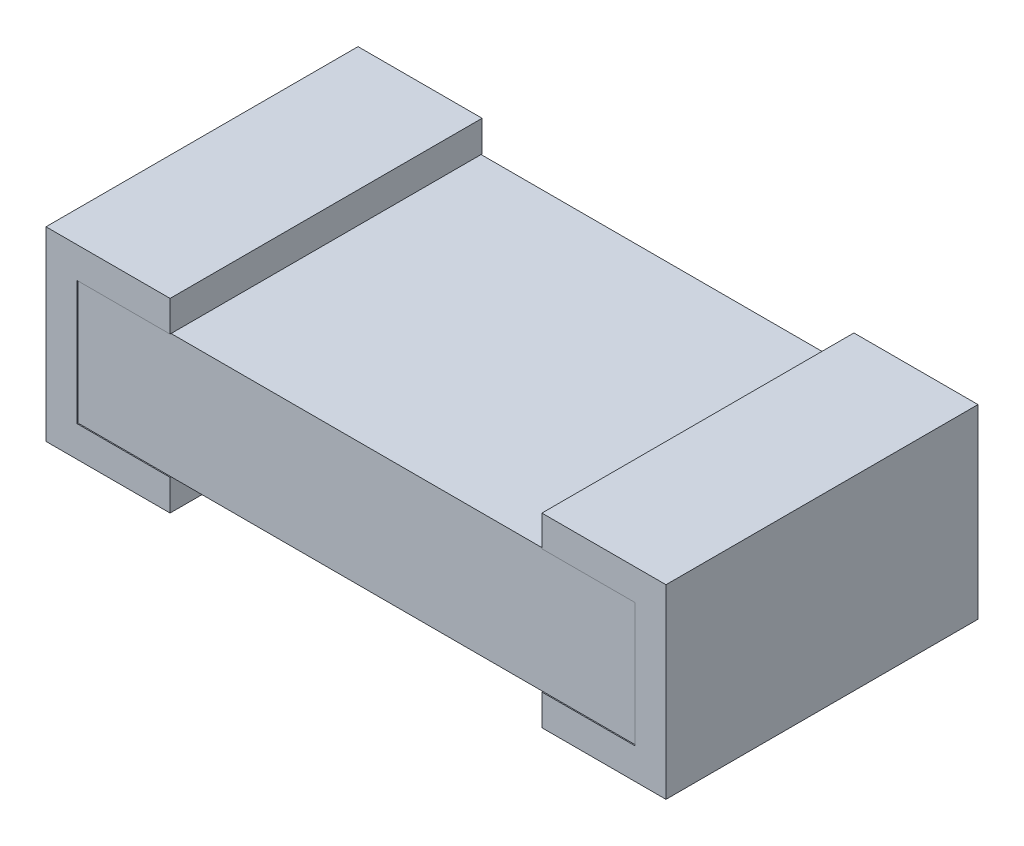
from build123d import *

# Parameters (mm, degrees)
ESBO_O1_W                = 1.372
ESBO_O1_H                = 0.305
RESSALTO_EXTRUS_O1_DEPTH = 0.381
RESSALTO_EXTRUS_O2_DEPTH = 0.3835


with BuildPart() as part:
    # Esboço1 → Ressalto-extrusão1 (new body, symmetric)
    with BuildSketch(Plane.XY):
        Rectangle(ESBO_O1_W, ESBO_O1_H)
    extrude(amount=RESSALTO_EXTRUS_O1_DEPTH, both=True)

    # Esboço2 → Ressalto-extrusão2 (add, symmetric)
    with BuildSketch(Plane.XY):
        Polygon((-0.457, 0.1525), (-0.686, 0.1525), (-0.686, -0.1525), (-0.457, -0.1525), (-0.457, -0.2285), (-0.762, -0.2285), (-0.762, 0.2285), (-0.457, 0.2285), align=None)
    ressalto_extrus_o2 = extrude(amount=RESSALTO_EXTRUS_O2_DEPTH, both=True)

    # Espelhar1: Ressalto-extrusão2 across plane
    add(ressalto_extrus_o2.mirror(Plane(origin=(0, 0, 0), x_dir=(0, 0, 1), z_dir=(1, 0, 0))))


solid = part.part
